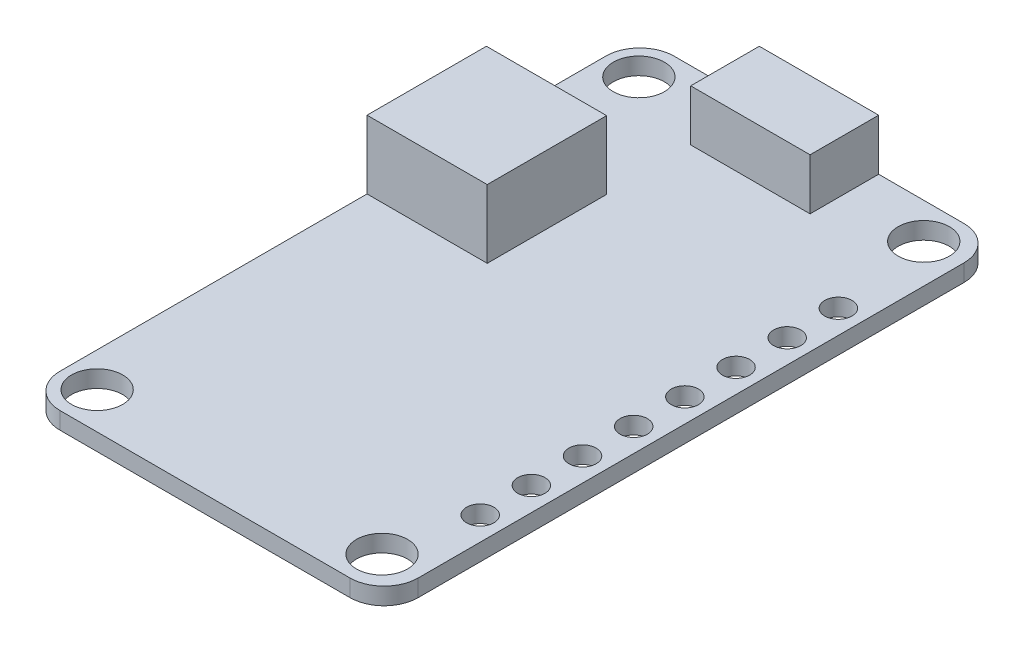
from build123d import *

# Parameters (mm, degrees)
CROQUIS1_W                 = 21
CROQUIS1_H                 = 36
SALIENTE_EXTRUIR1_DEPTH    = 5
CROQUIS2_OUTSIDE_W         = 31.396
CROQUIS2_OUTSIDE_H         = 46.396
CROQUIS2_OUTSIDE_W_2       = 7.048063548
CROQUIS2_OUTSIDE_H_2       = 7
CORTAR_EXTRUIR1_DEPTH      = 7
CORTAR_EXTRUIR1_DEPTH_BACK = 4
CROQUIS3_W                 = 7
CROQUIS3_H                 = 4.02225483
SALIENTE_EXTRUIR2_DEPTH    = 3
CROQUIS4_W                 = 5.679391124
CROQUIS4_H                 = 1.977645124
CORTAR_EXTRUIR2_DEPTH      = 3
CROQUIS5_W                 = 5.67716457
CROQUIS5_H                 = 2.946376549
CORTAR_EXTRUIR3_DEPTH      = 6
REDONDEO1_R                = 2
CROQUIS7_R                 = 1.5
CORTAR_EXTRUIR4_DEPTH      = 10
CROQUIS8_R                 = 1.5
CORTAR_EXTRUIR5_DEPTH      = 10
CROQUIS9_R                 = 0.798287554
CORTAR_EXTRUIR6_DEPTH      = 10
MATRIZL1_COUNT             = 8
MATRIZL1_PITCH             = 3


with BuildPart() as part:
    # Croquis1 → Saliente-Extruir1 (new body)
    with BuildSketch(Plane(origin=(0, 0, 0), x_dir=(1, 0, 0), z_dir=(0, 1, 0))):
        Rectangle(CROQUIS1_W, CROQUIS1_H)
    extrude(amount=SALIENTE_EXTRUIR1_DEPTH)

    # Croquis2 outside → Cortar-Extruir1 (cut, two sides)
    with BuildSketch(Plane(origin=(0, 5, 0), x_dir=(1, 0, 0), z_dir=(0, 1, 0))) as cortar_extruir1_sk:
        Rectangle(CROQUIS2_OUTSIDE_W, CROQUIS2_OUTSIDE_H)
        with Locations((-6.975968226, 5.5)):
            Rectangle(CROQUIS2_OUTSIDE_W_2, CROQUIS2_OUTSIDE_H_2, mode=Mode.SUBTRACT)
    extrude(amount=CORTAR_EXTRUIR1_DEPTH, mode=Mode.SUBTRACT)
    extrude(cortar_extruir1_sk.sketch, amount=-CORTAR_EXTRUIR1_DEPTH_BACK, mode=Mode.SUBTRACT)

    # Croquis3 → Saliente-Extruir2 (add)
    with BuildSketch(Plane(origin=(0, 1, 0), x_dir=(1, 0, 0), z_dir=(0, 1, 0))):
        with Locations((0, 15.988872585)):
            Rectangle(CROQUIS3_W, CROQUIS3_H)
    extrude(amount=SALIENTE_EXTRUIR2_DEPTH)

    # Croquis4 → Cortar-Extruir2 (cut)
    with BuildSketch(Plane(origin=(0, 0, -18), x_dir=(-1, 0, 0), z_dir=(0, 0, -1))):
        with Locations((0.114094911, 2.309841815)):
            Rectangle(CROQUIS4_W, CROQUIS4_H)
    extrude(amount=-CORTAR_EXTRUIR2_DEPTH, mode=Mode.SUBTRACT)

    # Croquis5 → Cortar-Extruir3 (cut)
    with BuildSketch(Plane.ZY.offset(10.5)):
        with Locations((-5.467429763, 2.848675026)):
            Rectangle(CROQUIS5_W, CROQUIS5_H)
    extrude(amount=-CORTAR_EXTRUIR3_DEPTH, mode=Mode.SUBTRACT)

    # Redondeo1
    redondeo1_edges = [part.edges().sort_by_distance(p)[0] for p in [
        (-10.5, 0.5, -18),
        (10.5, 0.5, -18),
        (10.5, 0.5, 18),
        (-10.5, 0.5, 18),
    ]]
    fillet(redondeo1_edges, radius=REDONDEO1_R)

    # Croquis7 → Cortar-Extruir4 (cut)
    with BuildSketch(Plane(origin=(0, 1, 0), x_dir=(1, 0, 0), z_dir=(0, 1, 0))):
        with Locations((-8.47455652, 15.912213441)):
            Circle(CROQUIS7_R)
    extrude(amount=-CORTAR_EXTRUIR4_DEPTH, mode=Mode.SUBTRACT)

    # Croquis8 → Cortar-Extruir5 (cut)
    with BuildSketch(Plane(origin=(0, 1, 0), x_dir=(1, 0, 0), z_dir=(0, 1, 0))):
        with Locations((8.231076472, 15.912213441)):
            Circle(CROQUIS8_R)
        with Locations((-8.47455652, -15.850727458)):
            Circle(CROQUIS8_R)
        with Locations((8.231076472, -15.850727458)):
            Circle(CROQUIS8_R)
    extrude(amount=-CORTAR_EXTRUIR5_DEPTH, mode=Mode.SUBTRACT)

    # Croquis9 → Cortar-Extruir6 (cut)
    with BuildSketch(Plane(origin=(0, 1, 0), x_dir=(1, 0, 0), z_dir=(0, 1, 0))):
        with Locations((9.121120171, -10.985155237)):
            Circle(CROQUIS9_R)
    cortar_extruir6 = extrude(amount=-CORTAR_EXTRUIR6_DEPTH, mode=Mode.SUBTRACT)

    # MatrizL1: Cortar-Extruir6 ×8
    with Locations(*[(0, 0, -i * MATRIZL1_PITCH) for i in range(1, MATRIZL1_COUNT)]):
        add(cortar_extruir6, mode=Mode.SUBTRACT)


solid = part.part
